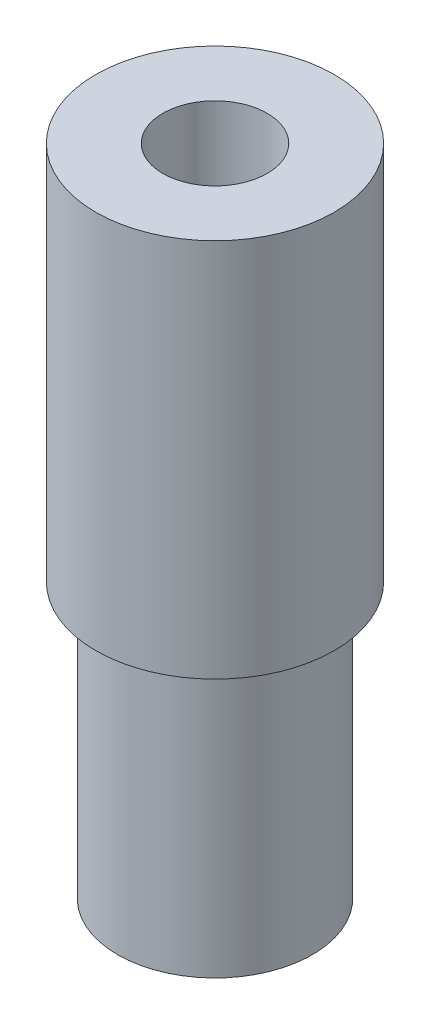
from build123d import *

# Parameters (mm, degrees)
SKETCH1_R           = 4.9
BOSS_EXTRUDE1_DEPTH = 13.8
SKETCH2_R           = 6
BOSS_EXTRUDE2_DEPTH = 19.1
SKETCH7_R           = 2.625
CUT_EXTRUDE1_DEPTH  = 33.9
CHAMFER1_SIZE       = 0.4


with BuildPart() as part:
    # Sketch1 → Boss-Extrude1 (new body)
    with BuildSketch(Plane(origin=(0, 0, 0), x_dir=(1, 0, 0), z_dir=(0, 1, 0))):
        Circle(SKETCH1_R)
    extrude(amount=BOSS_EXTRUDE1_DEPTH)

    # Sketch2 → Boss-Extrude2 (add)
    with BuildSketch(Plane(origin=(0, 13.8, 0), x_dir=(1, 0, 0), z_dir=(0, 1, 0))):
        Circle(SKETCH2_R)
    extrude(amount=BOSS_EXTRUDE2_DEPTH)

    # Sketch7 → Cut-Extrude1 (cut, through all)
    with BuildSketch(Plane(origin=(0, 0, 0), x_dir=(1, 0, 0), z_dir=(0, 1, 0))):
        Circle(SKETCH7_R)
    extrude(amount=CUT_EXTRUDE1_DEPTH, mode=Mode.SUBTRACT)

    # Chamfer1
    chamfer1_edges = [part.edges().sort_by_distance(p)[0] for p in [
        (-2.625, 0, 0),
    ]]
    chamfer(chamfer1_edges, length=CHAMFER1_SIZE)


solid = part.part
